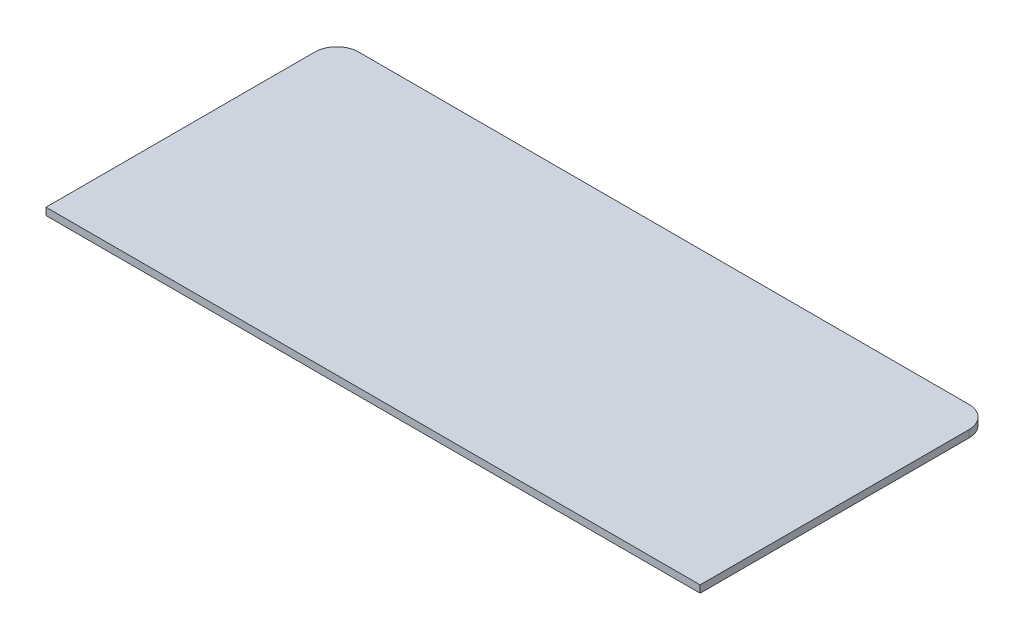
from build123d import *

# Parameters (mm, degrees)
BOSS_EXTRUDE1_DEPTH = 0.1


with BuildPart() as part:
    # Sketch1 → Boss-Extrude1 (new body)
    with BuildSketch(Plane(origin=(0, 0, 0), x_dir=(1, 0, 0), z_dir=(0, 1, 0))):
        with BuildLine():
            Line((0, 0), (4.5, 0))
            Line((4.5, 0), (4.5, 3.7))
            ThreePointArc((4.5, 3.7), (4.412132034, 3.912132034), (4.2, 4))
            Line((4.2, 4), (-4.2, 4))
            ThreePointArc((-4.2, 4), (-4.412132034, 3.912132034), (-4.5, 3.7))
            Line((-4.5, 3.7), (-4.5, 0))
            Line((-4.5, 0), (0, 0))
        make_face()
    extrude(amount=BOSS_EXTRUDE1_DEPTH)


solid = part.part
